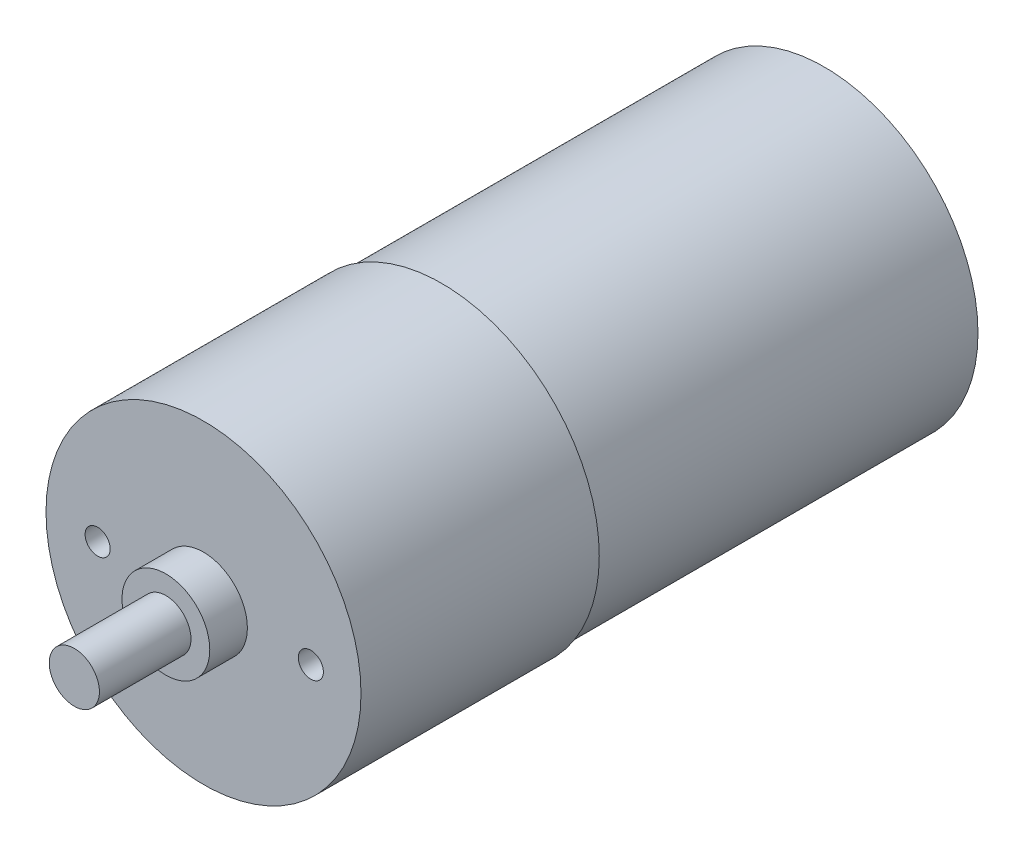
from build123d import *

# Parameters (mm, degrees)
SKETCH1_W          = 7.3
SKETCH1_H          = 2
SKETCH1_W_2        = 2.1
SKETCH2_R          = 1
CUT_EXTRUDE1_DEPTH = 2.54


with BuildPart() as part:
    # Sketch1 → Revolve3 (revolve)
    with BuildSketch(Plane(origin=(0, 0, 0), x_dir=(0, 0, -1), z_dir=(1, 0, 0)), mode=Mode.PRIVATE) as revolve3_sk:
        Polygon((-2765.109283147, 1456.751931389), (-2795.609283147, 1456.751931389), (-2795.609283147, 1444.551931389), (-2795.609283147, 1444.492861389), (-2765.109283147, 1444.492861389), (-2765.109283147, 1446.492861389), align=None)
        Polygon((-2795.609283147, 1444.551931389), (-2795.609283147, 1456.751931389), (-2795.609283147, 1457.051931389), (-2814.609283147, 1457.051931389), (-2814.609283147, 1447.992731389), (-2814.609283147, 1444.492861389), (-2795.609283147, 1444.492861389), align=None)
        Polygon((-2814.609283147, 1444.492861389), (-2814.609283147, 1447.992731389), (-2817.609283147, 1447.992731389), (-2817.609283147, 1446.492861389), (-2817.609283147, 1444.492861389), align=None)
        with Locations((-2821.259283147, 1445.492861389)):
            Rectangle(SKETCH1_W, SKETCH1_H)
        with Locations((-2764.059283147, 1445.492861389)):
            Rectangle(SKETCH1_W_2, SKETCH1_H)
    revolve(revolve3_sk.sketch.rotate(Axis((0, 1444.492861389, 2824.909283147), (0, 0, -1)), 90), axis=Axis((0, 1444.492861389, 2824.909283147), (0, 0, -1)))  # turned: the seam where the file's is

    # Sketch2 → Cut-Extrude1 (cut)
    with BuildSketch(Plane.XY.offset(2814.609283147)):
        with Locations((8.55907, 1444.492861389)):
            Circle(SKETCH2_R)
        with Locations((-8.44093, 1444.492861389)):
            Circle(SKETCH2_R)
    extrude(amount=-CUT_EXTRUDE1_DEPTH, mode=Mode.SUBTRACT)


solid = part.part
